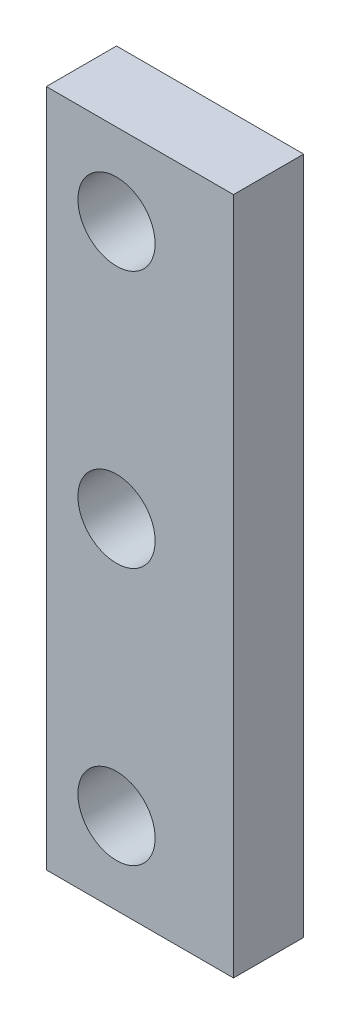
from build123d import *

# Parameters (mm, degrees)
ESBO_O1_W                = 8
ESBO_O1_H                = 29
ESBO_O1_R                = 1.65
RESSALTO_EXTRUS_O1_DEPTH = 3


with BuildPart() as part:
    # Esboço1 → Ressalto-extrusão1 (new body)
    with BuildSketch(Plane.XY):
        with Locations((4, 0)):
            Rectangle(ESBO_O1_W, ESBO_O1_H)
        with Locations((3, 11)):
            Circle(ESBO_O1_R, mode=Mode.SUBTRACT)
        with Locations((3, 0)):
            Circle(ESBO_O1_R, mode=Mode.SUBTRACT)
        with Locations((3, -11)):
            Circle(ESBO_O1_R, mode=Mode.SUBTRACT)
    extrude(amount=RESSALTO_EXTRUS_O1_DEPTH)


solid = part.part
